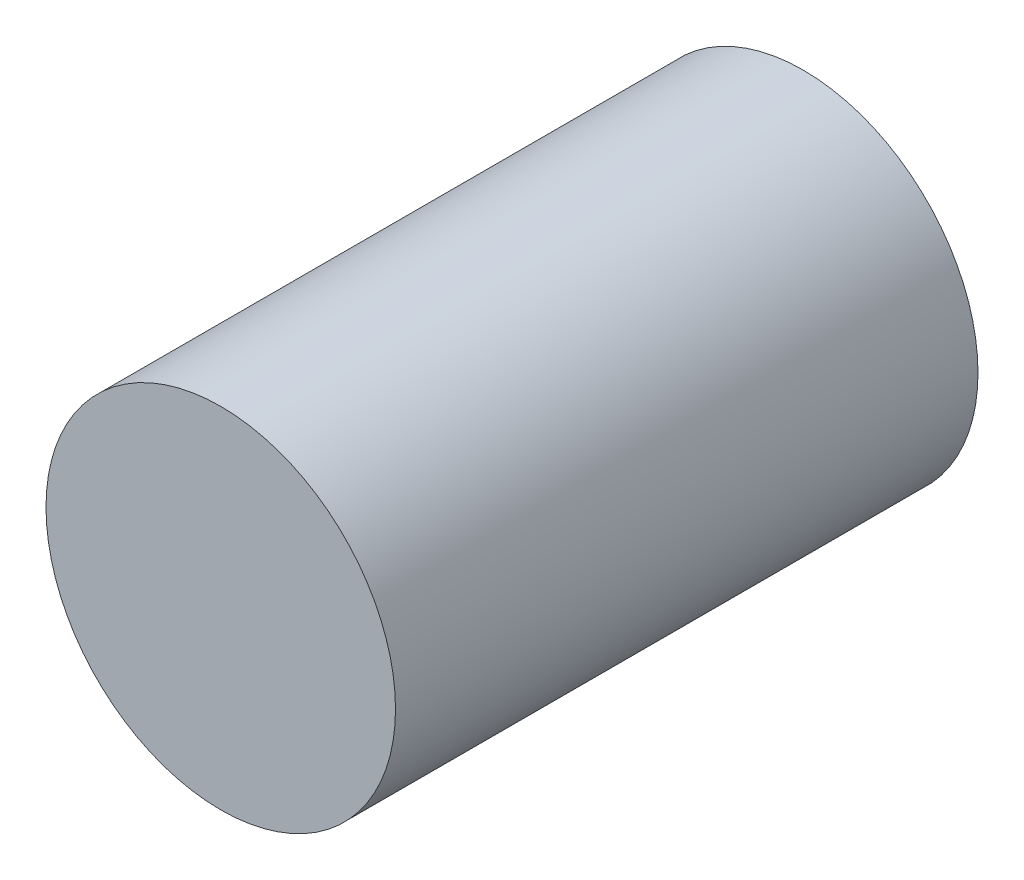
from build123d import *

# Parameters (mm, degrees)
SKETCH_1_R      = 0.3
EXTRUDE_1_DEPTH = 1


with BuildPart() as part:
    # 草图1 → 凸台-拉伸1 (new body)
    with BuildSketch(Plane.XY):
        with Locations((1.554285714, 0)):
            Circle(SKETCH_1_R)
    extrude(amount=EXTRUDE_1_DEPTH)


solid = part.part
